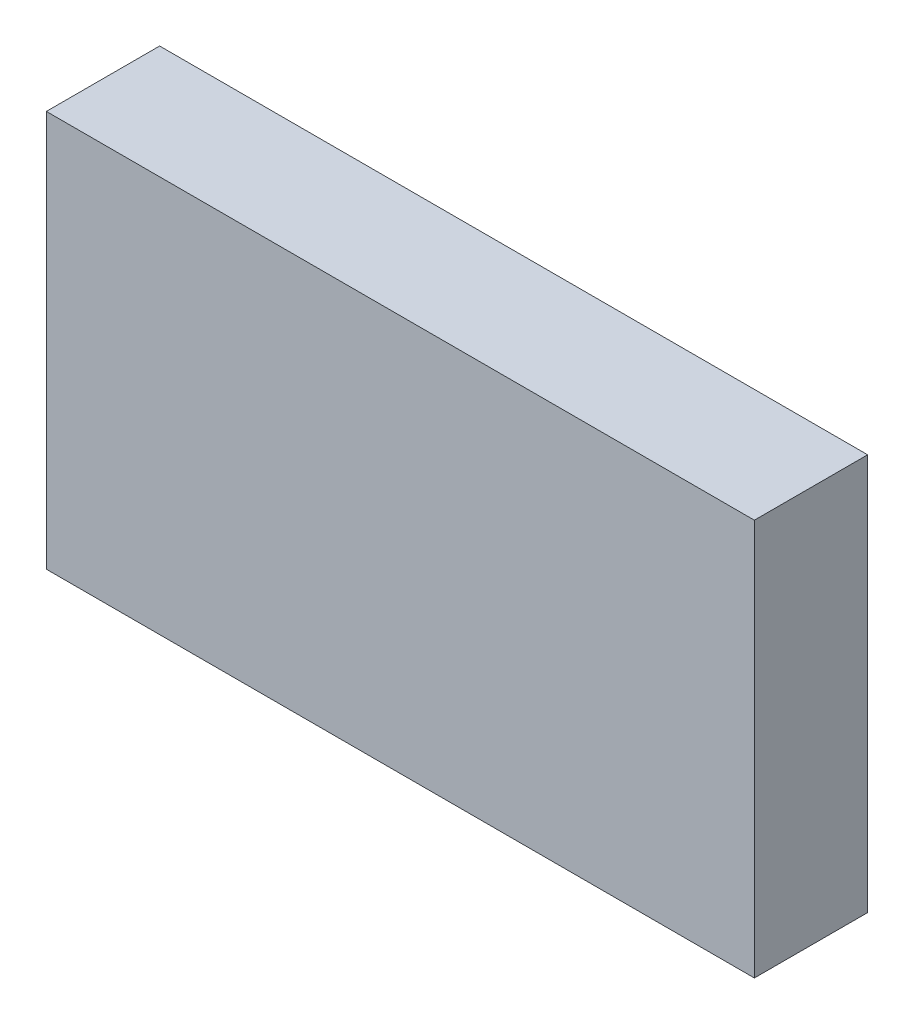
from build123d import *

# Parameters (mm, degrees)
SKETCH_1_W      = 12.5
SKETCH_1_H      = 7
EXTRUDE_1_DEPTH = 2


with BuildPart() as part:
    # Эскиз1 → Бобышка-Вытянуть1 (new body)
    with BuildSketch(Plane.XY):
        with Locations((6.25, 3.5)):
            Rectangle(SKETCH_1_W, SKETCH_1_H)
    extrude(amount=EXTRUDE_1_DEPTH)


solid = part.part
